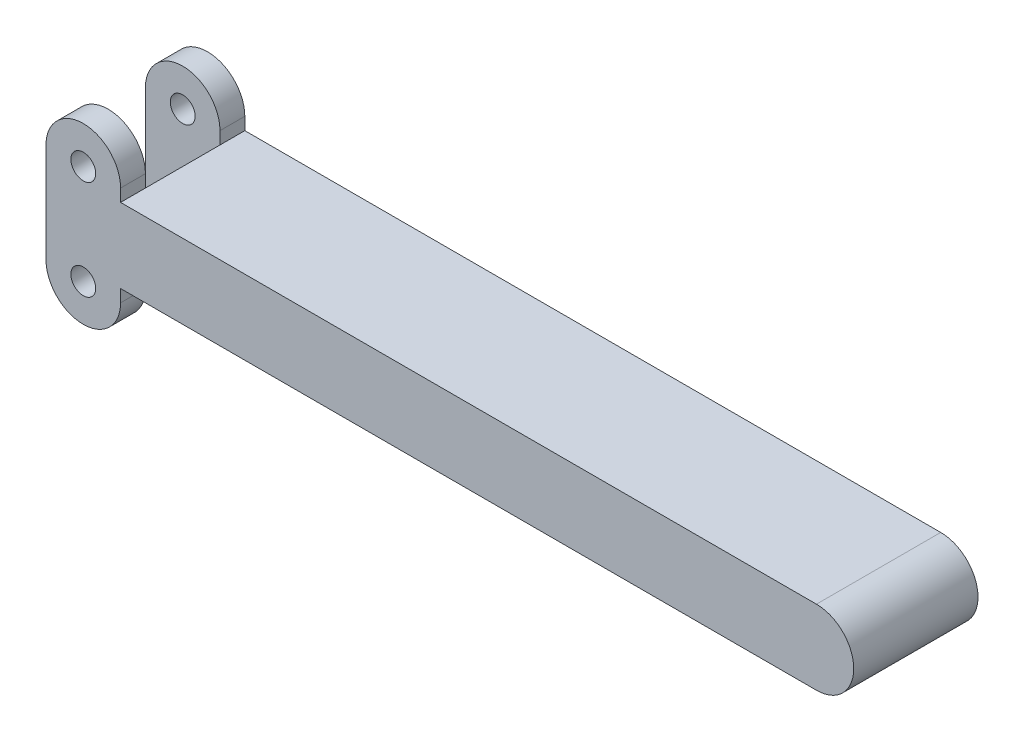
from build123d import *

# Parameters (mm, degrees)
SKETCH1_R           = 3.175
BOSS_EXTRUDE1_DEPTH = 31.75
SKETCH2_W           = 19.05
SKETCH2_H           = 25.4
SKETCH2_H_2         = 9.525
CUT_EXTRUDE1_DEPTH  = 19.05


with BuildPart() as part:
    # Sketch1 → Boss-Extrude1 (new body)
    with BuildSketch(Plane.XY):
        with BuildLine():
            Line((-9.525, 25.4), (-9.525, 0))
            ThreePointArc((-9.525, 0), (0, -9.525), (9.525, 0))
            Line((9.525, 0), (9.525, 3.175))
            Line((9.525, 3.175), (187.325, 3.175))
            ThreePointArc((187.325, 3.175), (196.85, 12.7), (187.325, 22.225))
            Line((187.325, 22.225), (9.525, 22.225))
            Line((9.525, 22.225), (9.525, 25.4))
            ThreePointArc((9.525, 25.4), (0, 34.925), (-9.525, 25.4))
        make_face()
        Circle(SKETCH1_R, mode=Mode.SUBTRACT)
        with Locations((0, 25.4)):
            Circle(SKETCH1_R, mode=Mode.SUBTRACT)
    extrude(amount=BOSS_EXTRUDE1_DEPTH)

    # Sketch2 → Cut-Extrude1 (cut)
    with BuildSketch(Plane.ZY.offset(9.525)):
        with Locations((15.875, 12.7)):
            Rectangle(SKETCH2_W, SKETCH2_H)
        with Locations((15.875, 30.1625)):
            Rectangle(SKETCH2_W, SKETCH2_H_2)
        with Locations((15.875, -4.7625)):
            Rectangle(SKETCH2_W, SKETCH2_H_2)
    extrude(amount=-CUT_EXTRUDE1_DEPTH, mode=Mode.SUBTRACT)


solid = part.part
